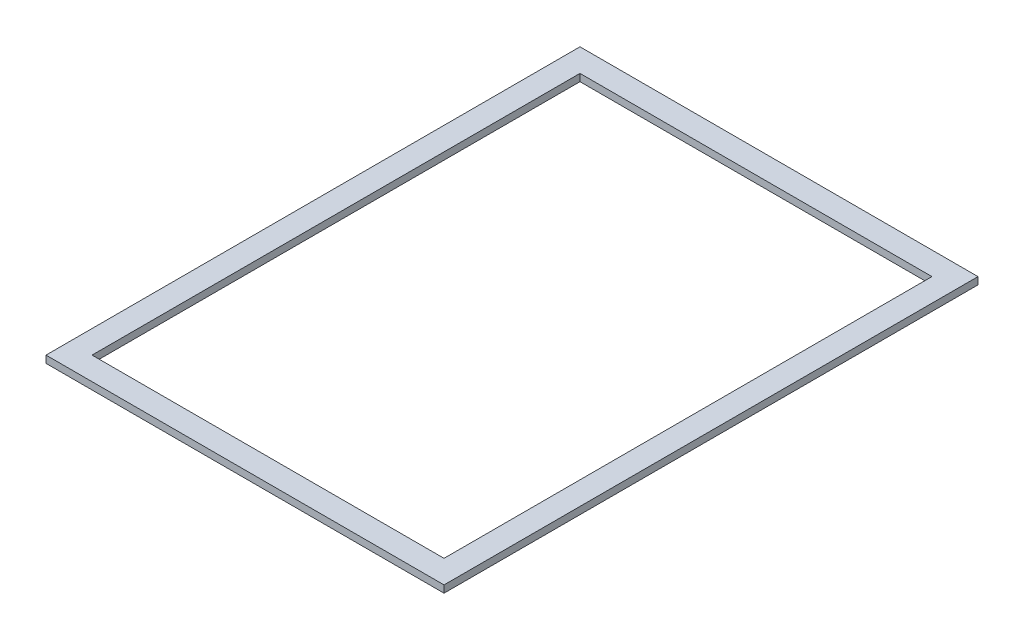
from build123d import *

# Parameters (mm, degrees)
SKETCH1_W           = 87.828
SKETCH1_H           = 117.828
SKETCH1_W_2         = 77.668
SKETCH1_H_2         = 107.668
BOSS_EXTRUDE1_DEPTH = 1.5875


with BuildPart() as part:
    # Sketch1 → Boss-Extrude1 (new body)
    with BuildSketch(Plane(origin=(0, 129.032, 0), x_dir=(1, 0, 0), z_dir=(0, 1, 0))):
        with Locations((43.914, 58.914)):
            Rectangle(SKETCH1_W, SKETCH1_H)
        with Locations((43.914, 58.914)):
            Rectangle(SKETCH1_W_2, SKETCH1_H_2, mode=Mode.SUBTRACT)
    extrude(amount=BOSS_EXTRUDE1_DEPTH)


solid = part.part
